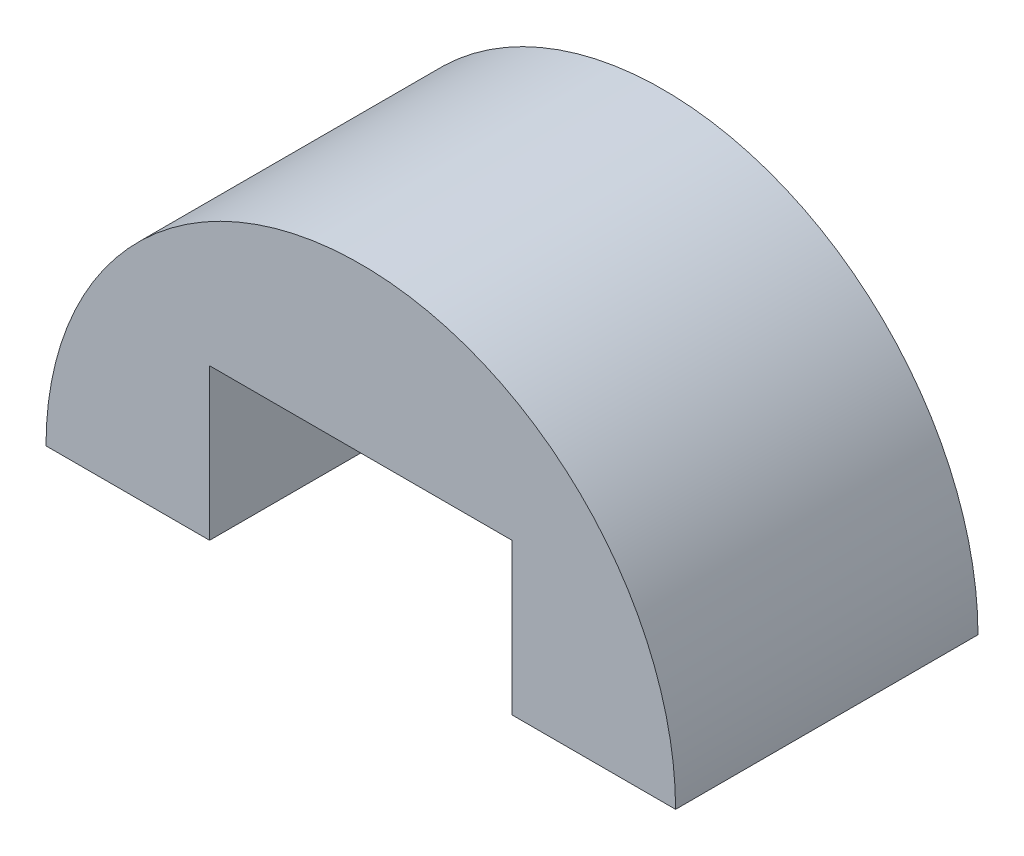
from build123d import *

# Parameters (mm, degrees)
BOSS_EXTRUDE1_DEPTH = 6


with BuildPart() as part:
    # Model → Boss-Extrude1 (new body)
    with BuildSketch(Plane.XY):
        with BuildLine():
            Line((3818.619566465, 1740.47224219), (3821.865215459, 1740.47224219))
            Line((3821.865215459, 1740.47224219), (3821.865215459, 1743.47224219))
            Line((3821.865215459, 1743.47224219), (3827.865215459, 1743.47224219))
            Line((3827.865215459, 1743.47224219), (3827.865215459, 1740.47224219))
            Line((3827.865215459, 1740.47224219), (3831.110864454, 1740.47224219))
            ThreePointArc((3831.110864454, 1740.47224219), (3824.865215459, 1746.717891184), (3818.619566465, 1740.47224219))
        make_face()
    extrude(amount=BOSS_EXTRUDE1_DEPTH)


solid = part.part
